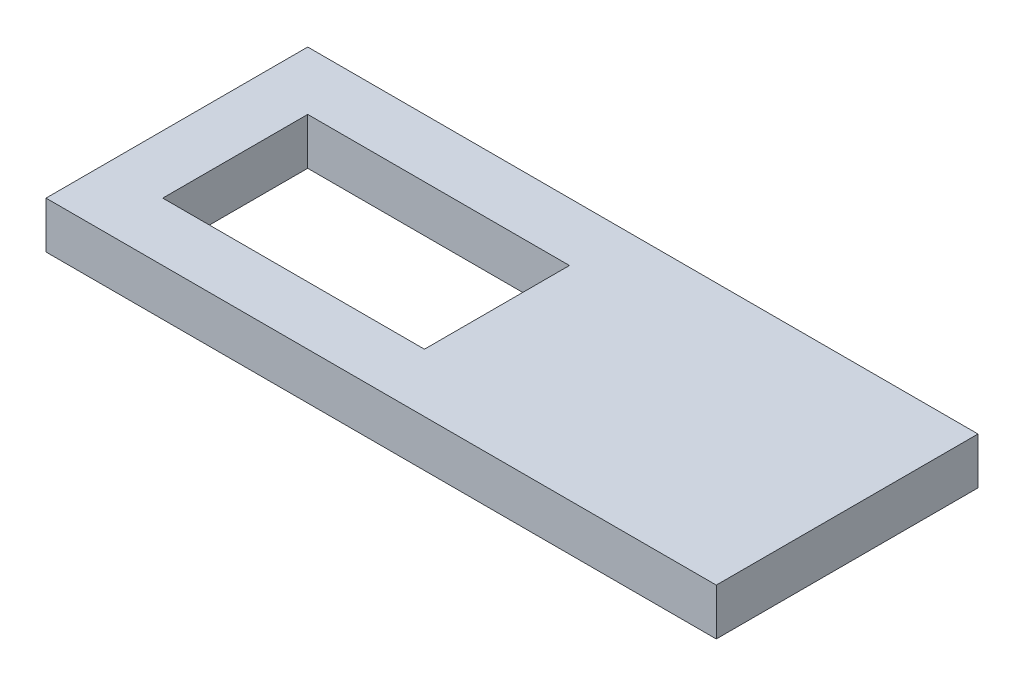
from build123d import *

# Parameters (mm, degrees)
SKETCH1_W           = 57.42
SKETCH1_H           = 22.42
SKETCH1_W_2         = 22.42
SKETCH1_H_2         = 12.42
BOSS_EXTRUDE1_DEPTH = 4


with BuildPart() as part:
    # Sketch1 → Boss-Extrude1 (new body)
    with BuildSketch(Plane(origin=(0, 0, 0), x_dir=(1, 0, 0), z_dir=(0, 1, 0))):
        with Locations((23.71, 6.21)):
            Rectangle(SKETCH1_W, SKETCH1_H)
        with Locations((11.21, 6.21)):
            Rectangle(SKETCH1_W_2, SKETCH1_H_2, mode=Mode.SUBTRACT)
    extrude(amount=BOSS_EXTRUDE1_DEPTH)


solid = part.part
